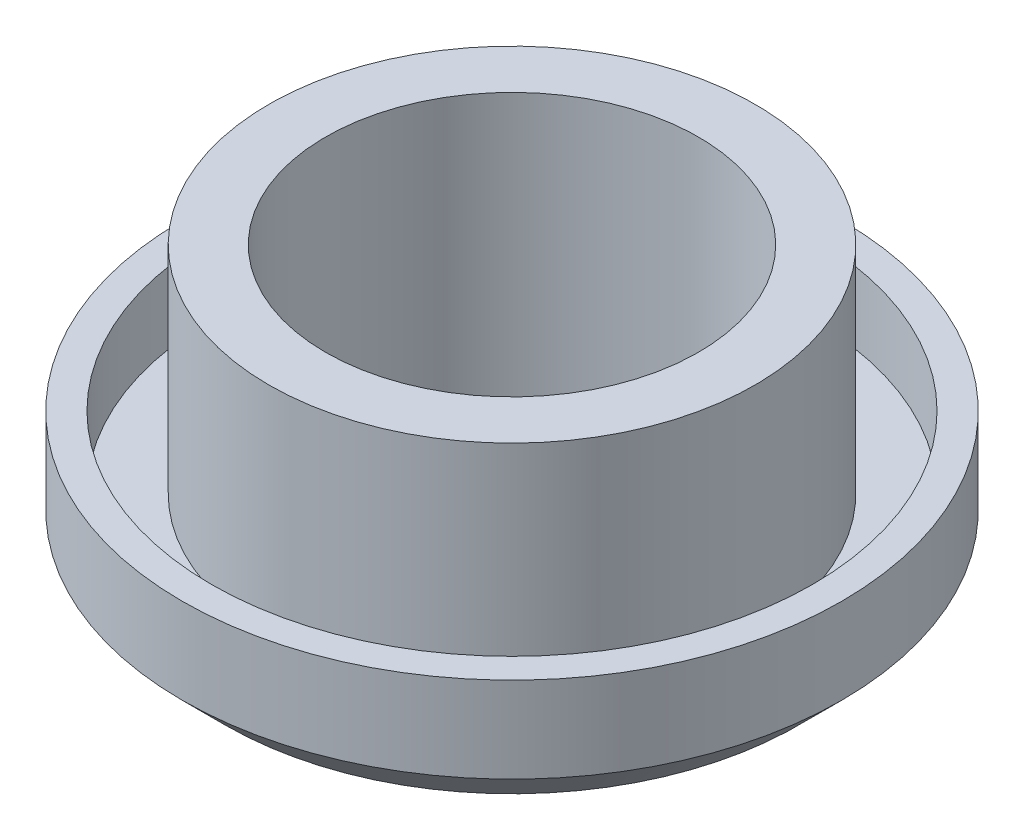
from build123d import *

# Parameters (mm, degrees)
CHAMFER1_SIZE = 5.2


with BuildPart() as part:
    # Sketch1 → Revolve1 (revolve)
    with BuildSketch(Plane.XY):
        Polygon((-11.59722846, 17.3), (-4.79722846, 17.3), (-4.79722846, -15.5), (-21.99722846, -15.5), (-21.99722846, 0), (-18.49722846, 0), (-18.49722846, -8.6), (-11.59722846, -8.6), align=None)
    revolve(axis=Axis((17.60277154, 25.472027778, 0), (0, -1, 0)))

    # Chamfer1
    chamfer1_edges = [part.edges().sort_by_distance(p)[0] for p in [
        (57.20277154, -15.5, 0),
    ]]
    chamfer(chamfer1_edges, length=CHAMFER1_SIZE)


solid = part.part
